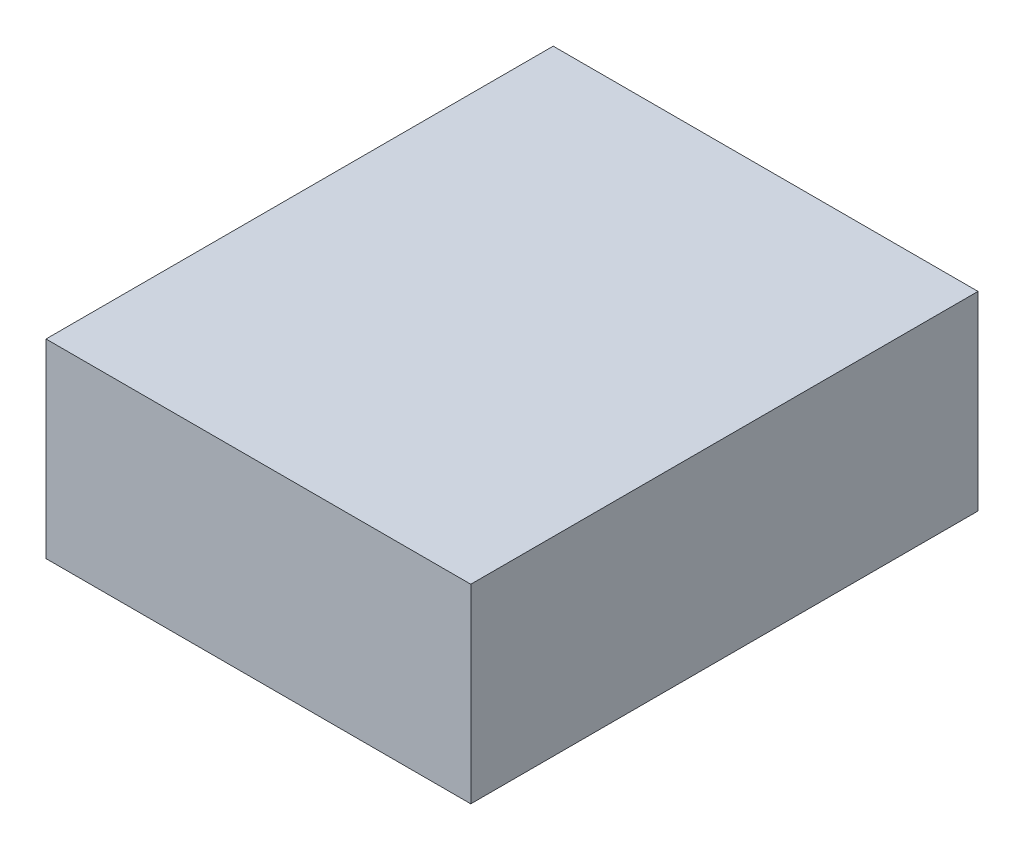
from build123d import *

# Parameters (mm, degrees)
SKETCH1_W      = 17.018
SKETCH1_H      = 20.32
EXTRUDE1_DEPTH = 7.62


with BuildPart() as part:
    # Sketch1 → Extrude1 (new body)
    with BuildSketch(Plane(origin=(0, 0, 0), x_dir=(1, 0, 0), z_dir=(0, 1, 0))):
        Rectangle(SKETCH1_W, SKETCH1_H)
    extrude(amount=EXTRUDE1_DEPTH)


solid = part.part
